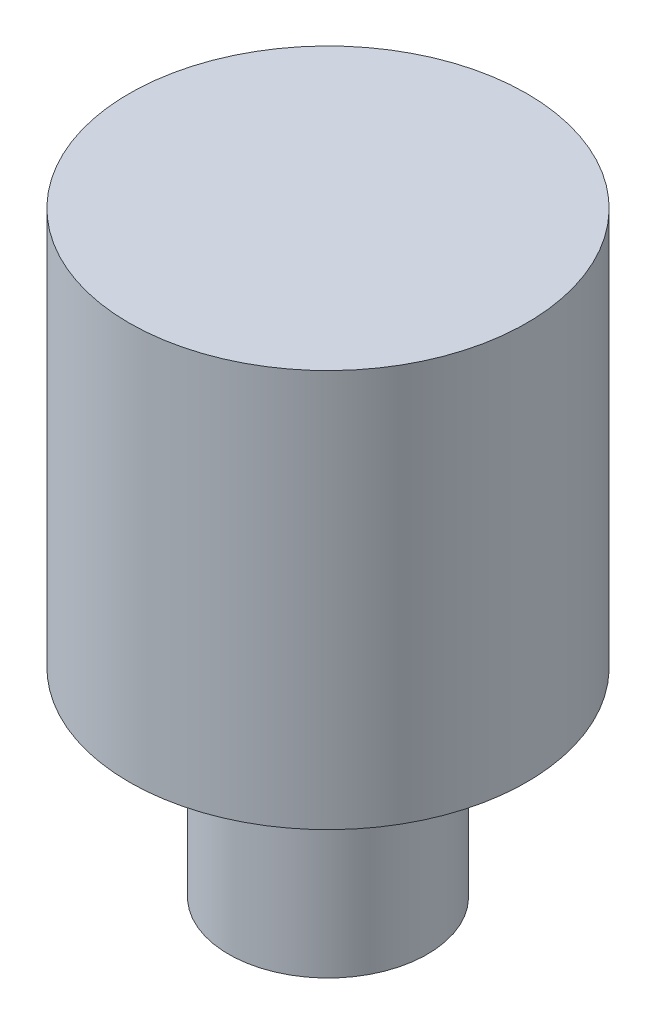
from build123d import *

# Parameters (mm, degrees)
SKETCH1_W = 2
SKETCH1_H = 6
SKETCH2_W = 1
SKETCH2_H = 2


with BuildPart() as part:
    # Sketch1 → Revolve1 (revolve)
    with BuildSketch(Plane.XY):
        with Locations((1, 3)):
            Rectangle(SKETCH1_W, SKETCH1_H)
    revolve(axis=Axis((0, 0, 0), (0, 1, 0)))

    # Sketch2 → Cut-Revolve1 (revolve, cut)
    with BuildSketch(Plane.XY):
        with Locations((1.5, 1)):
            Rectangle(SKETCH2_W, SKETCH2_H)
    revolve(axis=Axis((0, 0, 0), (0, 1, 0)), mode=Mode.SUBTRACT)


solid = part.part
